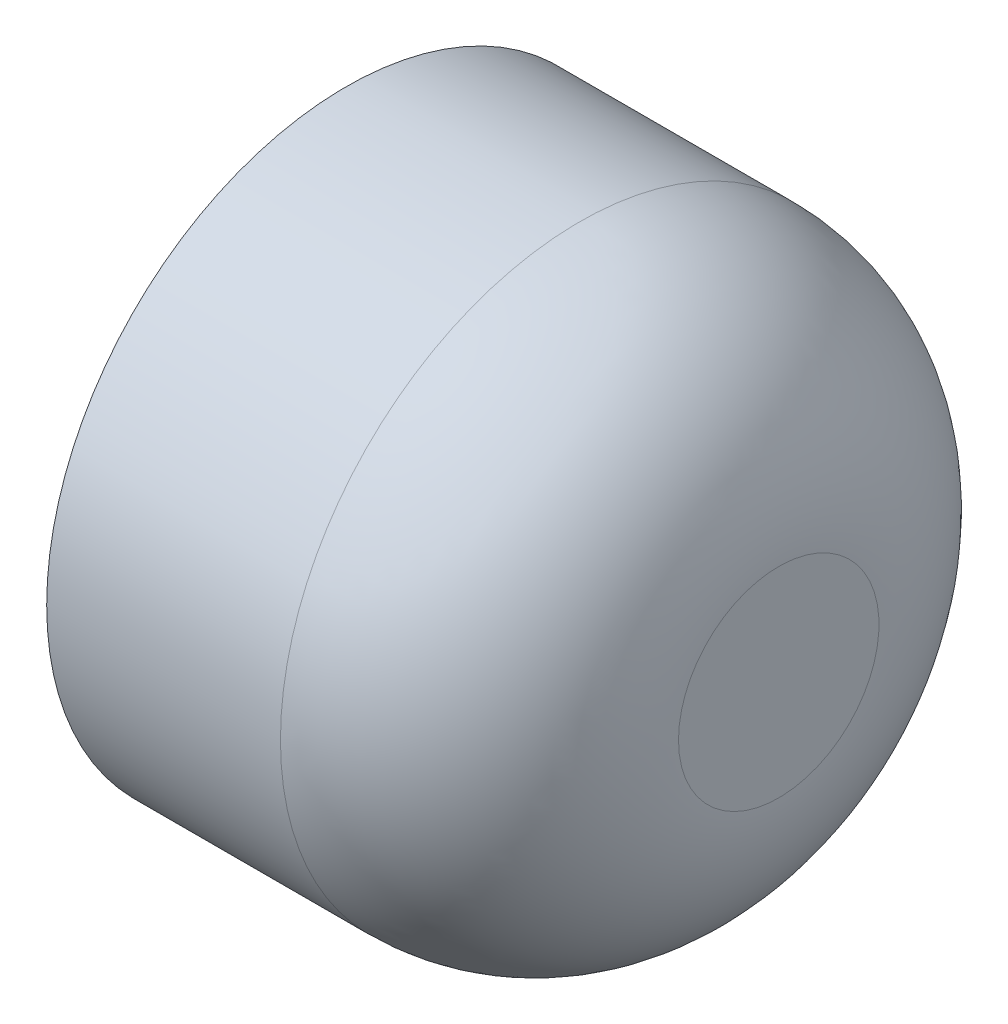
from build123d import *


with BuildPart() as part:
    # Sketch1 → Revolve1 (revolve)
    with BuildSketch(Plane.XY):
        with BuildLine():
            Line((-18.46180283, 41.427938133), (-18.46180283, 39.292822958))
            Line((-18.46180283, 39.292822958), (13.936626274, 39.292822958))
            ThreePointArc((13.936626274, 39.292822958), (30.972595004, 28.542181462), (37.613580664, 9.523826312))
            Line((37.613580664, 9.523826312), (37.613580664, 0))
            Line((37.613580664, 0), (41.446234578, 0))
            Line((41.446234578, 0), (41.446234578, 13.87712105))
            ThreePointArc((41.446234578, 13.87712105), (33.376787082, 33.358490637), (13.895417495, 41.427938133))
            Line((13.895417495, 41.427938133), (-18.46180283, 41.427938133))
        make_face()
    revolve(axis=Axis((0, 0, 0), (1, 0, 0)))


solid = part.part
